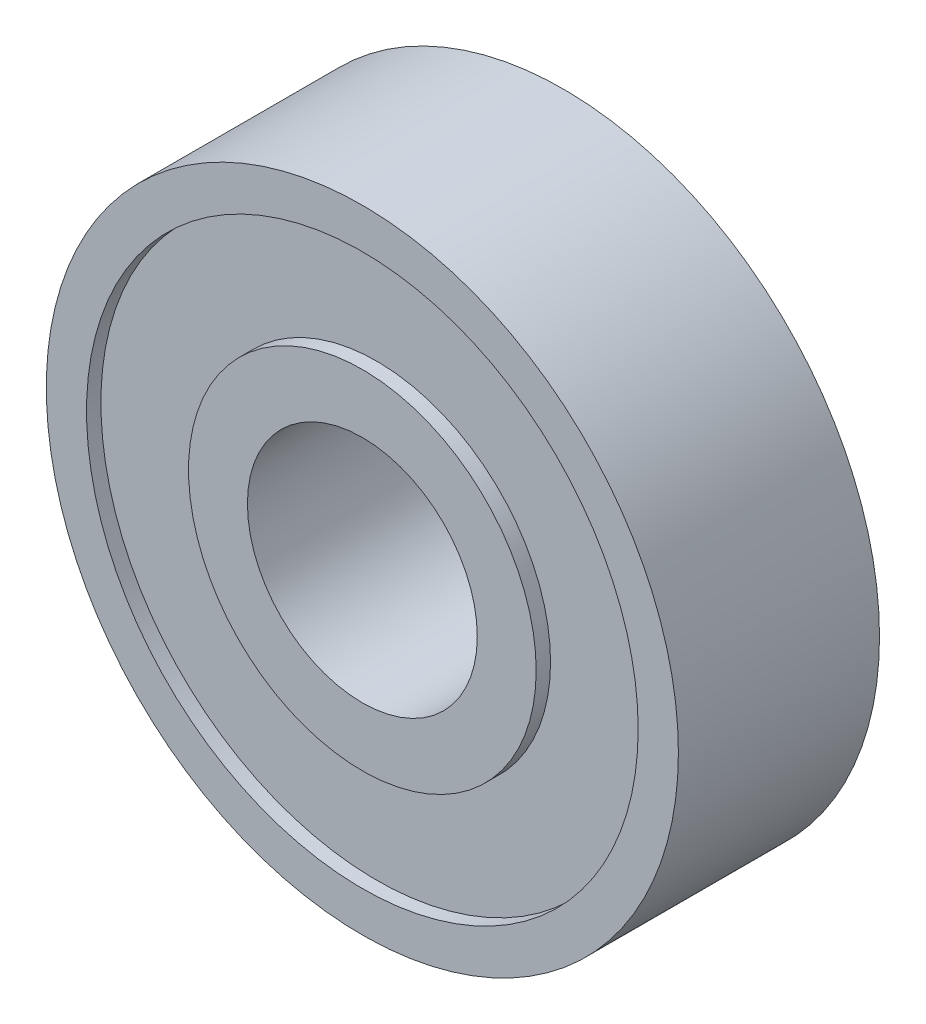
from build123d import *

# Parameters (mm, degrees)
SKETCH_1_R          = 11
EXTRUDE_1_DEPTH     = 3.5
SKETCH_2_R          = 4
CUT_EXTRUDE_1_DEPTH = 8
SKETCH_3_R          = 9.6
SKETCH_3_R_2        = 6.05
CUT_EXTRUDE_2_DEPTH = 0.5


with BuildPart() as part:
    # 草圖1 → 填料-伸長1 (new body, symmetric)
    with BuildSketch(Plane.XY):
        Circle(SKETCH_1_R)
    extrude(amount=EXTRUDE_1_DEPTH, both=True)

    # 草圖2 → 除料-伸長1 (cut, through all)
    with BuildSketch(Plane.XY.offset(3.5)):
        Circle(SKETCH_2_R)
    extrude(amount=-CUT_EXTRUDE_1_DEPTH, mode=Mode.SUBTRACT)

    # 草圖3 → 除料-伸長2 (cut)
    with BuildSketch(Plane.XY.offset(3.5)):
        Circle(SKETCH_3_R)
        Circle(SKETCH_3_R_2, mode=Mode.SUBTRACT)
    cut_extrude_2 = extrude(amount=-CUT_EXTRUDE_2_DEPTH, mode=Mode.SUBTRACT)

    # 鏡射1: 除料-伸長2 across plane
    add(cut_extrude_2.mirror(Plane.XY), mode=Mode.SUBTRACT)


solid = part.part
